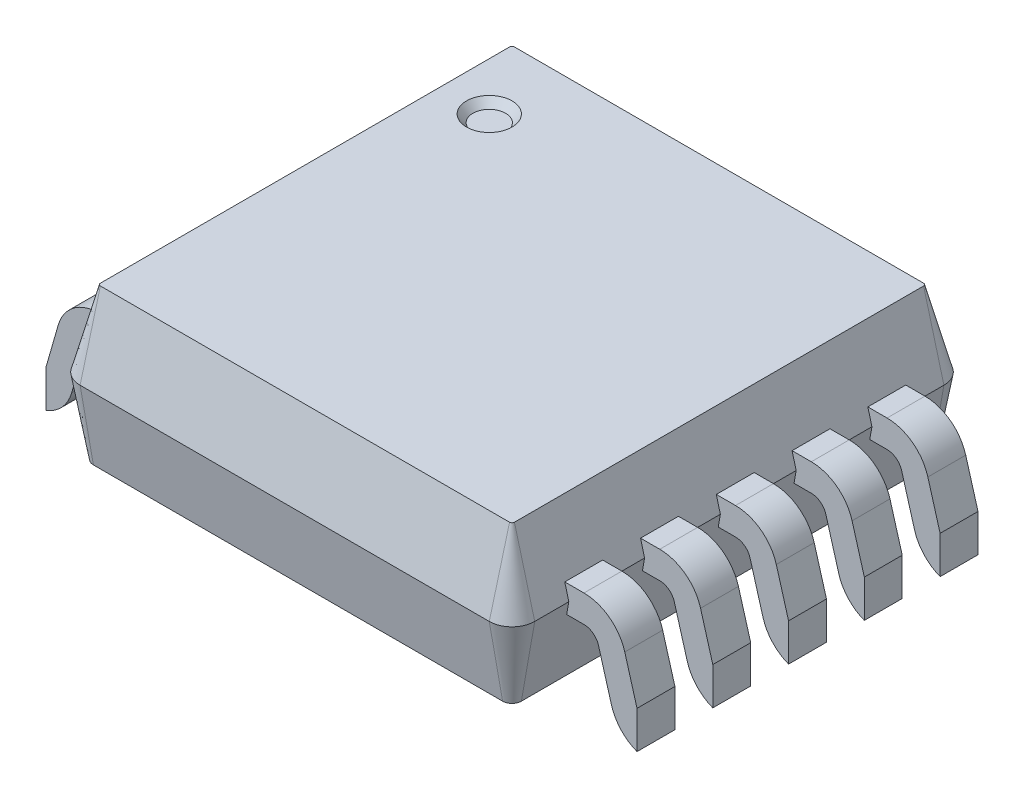
from build123d import *

# Parameters (mm, degrees)
EXTRUDE1_START           = 0.65
EXTRUDE1_DEPTH           = 0.5
EXTRUDE1_TAPER           = 15
EXTRUDE1_OTHER_WAY_DEPTH = 0.5
EXTRUDE1_OTHER_WAY_TAPER = 10
ICE1_START               = 1
ICE1_DEPTH               = 0.125
LPATTERN1_COUNT          = 5
LPATTERN1_PITCH          = 0.5
SKETCH2_R                = 0.15
ICE2_DEPTH               = 0.05
ICE2_TAPER               = 40
SKETCH4_W                = 9.36370073
SKETCH4_H                = 1.137163533
CUT_EXTRUDE1_DEPTH       = 0.5
SKETCH5_W                = 6.001944726
SKETCH5_H                = 0.666405747
CUT_EXTRUDE2_DEPTH       = 0.5


with BuildPart() as part:
    # Sketch1 → Extrude1 (new body)
    with BuildSketch(Plane(origin=(0, 0, 0), x_dir=(1, 0, 0), z_dir=(0, 1, 0)).offset(EXTRUDE1_START)):
        with BuildLine():
            ThreePointArc((-1.35, 1.5), (-1.456066017, 1.456066017), (-1.5, 1.35))
            Line((-1.5, 1.35), (-1.5, -1.35))
            ThreePointArc((-1.5, -1.35), (-1.456066017, -1.456066017), (-1.35, -1.5))
            Line((-1.35, -1.5), (1.35, -1.5))
            ThreePointArc((1.35, -1.5), (1.456066017, -1.456066017), (1.5, -1.35))
            Line((1.5, -1.35), (1.5, 1.35))
            ThreePointArc((1.5, 1.35), (1.456066017, 1.456066017), (1.35, 1.5))
            Line((1.35, 1.5), (-1.35, 1.5))
        make_face()
    extrude(amount=EXTRUDE1_DEPTH, taper=EXTRUDE1_TAPER)

    # Sketch1 → Extrude1 other way (add)
    with BuildSketch(Plane(origin=(0, 0, 0), x_dir=(1, 0, 0), z_dir=(0, 1, 0)).offset(EXTRUDE1_START)):
        with BuildLine():
            ThreePointArc((-1.35, 1.5), (-1.456066017, 1.456066017), (-1.5, 1.35))
            Line((-1.5, 1.35), (-1.5, -1.35))
            ThreePointArc((-1.5, -1.35), (-1.456066017, -1.456066017), (-1.35, -1.5))
            Line((-1.35, -1.5), (1.35, -1.5))
            ThreePointArc((1.35, -1.5), (1.456066017, -1.456066017), (1.5, -1.35))
            Line((1.5, -1.35), (1.5, 1.35))
            ThreePointArc((1.5, 1.35), (1.456066017, 1.456066017), (1.35, 1.5))
            Line((1.35, 1.5), (-1.35, 1.5))
        make_face()
    extrude(amount=-EXTRUDE1_OTHER_WAY_DEPTH, taper=EXTRUDE1_OTHER_WAY_TAPER)

    # Sketch3 → ICE1 (add, symmetric)
    with BuildSketch(Plane.XY.offset(ICE1_START)):
        with BuildLine():
            Line((-2.45, 0), (-2.05, 0))
            ThreePointArc((-2.05, 0), (-1.881563475, 0.05632806), (-1.780896254, 0.202649022))
            Line((-1.780896254, 0.202649022), (-1.696108481, 0.497625349))
            ThreePointArc((-1.696108481, 0.497625349), (-1.660155902, 0.549882836), (-1.6, 0.57))
            Line((-1.6, 0.57), (-1.45, 0.57))
            Line((-1.45, 0.57), (-1.45, 0.75))
            Line((-1.45, 0.75), (-1.6, 0.75))
            ThreePointArc((-1.6, 0.75), (-1.768436525, 0.69367194), (-1.869103746, 0.547350978))
            Line((-1.869103746, 0.547350978), (-1.953891519, 0.252374651))
            ThreePointArc((-1.953891519, 0.252374651), (-1.989844098, 0.200117164), (-2.05, 0.18))
            Line((-2.05, 0.18), (-2.45, 0.18))
            Line((-2.45, 0.18), (-2.45, 0))
        make_face()
        with BuildLine():
            Line((1.45, 0.75), (1.6, 0.75))
            ThreePointArc((1.6, 0.75), (1.768436525, 0.69367194), (1.869103746, 0.547350978))
            Line((1.869103746, 0.547350978), (1.953891519, 0.252374651))
            ThreePointArc((1.953891519, 0.252374651), (1.989844098, 0.200117164), (2.05, 0.18))
            Line((2.05, 0.18), (2.45, 0.18))
            Line((2.45, 0.18), (2.45, 0))
            Line((2.45, 0), (2.05, 0))
            ThreePointArc((2.05, 0), (1.881563475, 0.05632806), (1.780896254, 0.202649022))
            Line((1.780896254, 0.202649022), (1.696108481, 0.497625349))
            ThreePointArc((1.696108481, 0.497625349), (1.660155902, 0.549882836), (1.6, 0.57))
            Line((1.6, 0.57), (1.45, 0.57))
            Line((1.45, 0.57), (1.45, 0.75))
        make_face()
    ice1 = extrude(amount=ICE1_DEPTH, both=True)

    # LPattern1: ICE1 ×5
    with Locations(*[(0, 0, -i * LPATTERN1_PITCH) for i in range(1, LPATTERN1_COUNT)]):
        add(ice1)

    # Sketch2 → ICE2 (cut)
    with BuildSketch(Plane(origin=(0, 1.15, 0), x_dir=(1, 0, 0), z_dir=(0, 1, 0))):
        with Locations((-1.05, 0.9)):
            Circle(SKETCH2_R)
    extrude(amount=-ICE2_DEPTH, taper=ICE2_TAPER, mode=Mode.SUBTRACT)

    # Sketch4 → Cut-Extrude1 (cut)
    with BuildSketch(Plane(origin=(2.45, 0, 0), x_dir=(0, 0, -1), z_dir=(1, 0, 0))):
        with Locations((-1.020096665, 0.094842565)):
            Rectangle(SKETCH4_W, SKETCH4_H)
    extrude(amount=-CUT_EXTRUDE1_DEPTH, mode=Mode.SUBTRACT)

    # Sketch5 → Cut-Extrude2 (cut)
    with BuildSketch(Plane.ZY.offset(2.45)):
        with Locations((0.974717588, 0.071546519)):
            Rectangle(SKETCH5_W, SKETCH5_H)
    extrude(amount=-CUT_EXTRUDE2_DEPTH, mode=Mode.SUBTRACT)


solid = part.part
